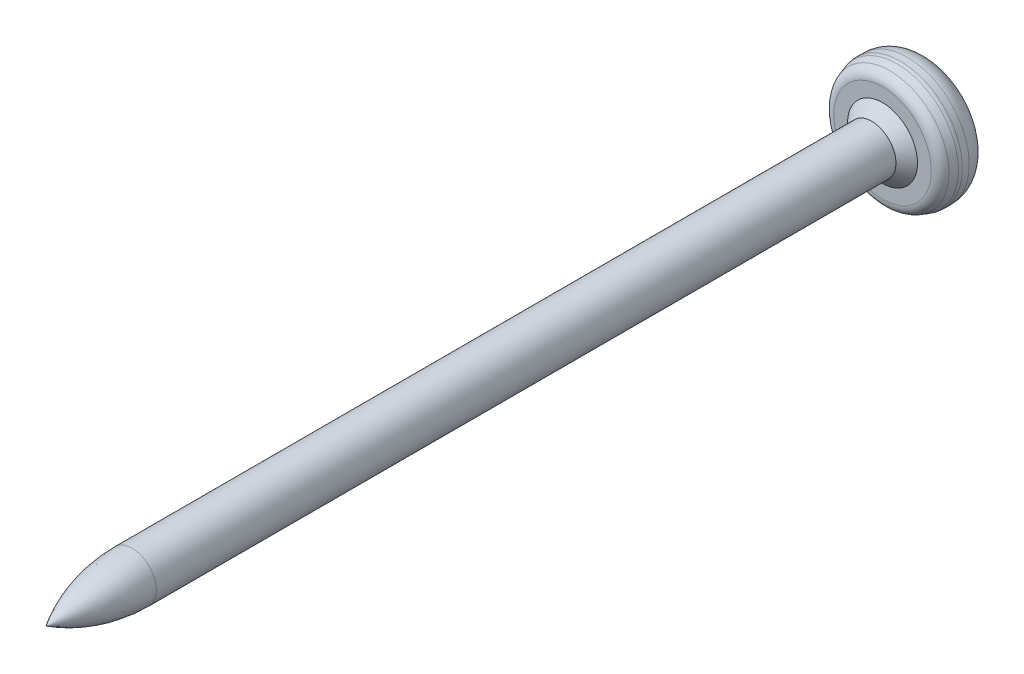
from build123d import *


with BuildPart() as part:
    # Skizze1 → Rotation1 (revolve)
    with BuildSketch(Plane(origin=(0, 0, 0), x_dir=(0, 0, -1), z_dir=(1, 0, 0)), mode=Mode.PRIVATE) as rotation1_sk:
        with BuildLine():
            Line((-0.006814835, 3.47456669), (-0.937822174, 0))
            Line((-0.937822174, 0), (-82, 0))
            ThreePointArc((-82, 0), (-78.155192535, 1.676795679), (-74, 2.25))
            Line((-74, 2.25), (-5.3, 2.25))
            Line((-5.3, 2.25), (-4.3, 3.25))
            Line((-4.3, 3.25), (-4.3, 4.52924078))
            ThreePointArc((-4.3, 4.52924078), (-4.111242185, 5.113951065), (-3.616227766, 5.477924078))
            Line((-3.616227766, 5.477924078), (-2.953950106, 5.698683298))
            ThreePointArc((-2.953950106, 5.698683298), (-2.797904583, 5.737087458), (-2.63772234, 5.75))
            Line((-2.63772234, 5.75), (-2, 5.75))
            ThreePointArc((-2, 5.75), (-0.585786438, 5.164213562), (0, 3.75))
            Line((0, 3.75), (0, 3.5263305))
            ThreePointArc((0, 3.5263305), (-0.001711028, 3.500225261), (-0.006814835, 3.47456669))
        make_face()
    revolve(rotation1_sk.sketch.rotate(Axis((0, 0, 0), (0, 0, 1)), 90), axis=Axis((0, 0, 0), (0, 0, 1)))  # turned: the seam where the file's is


solid = part.part
